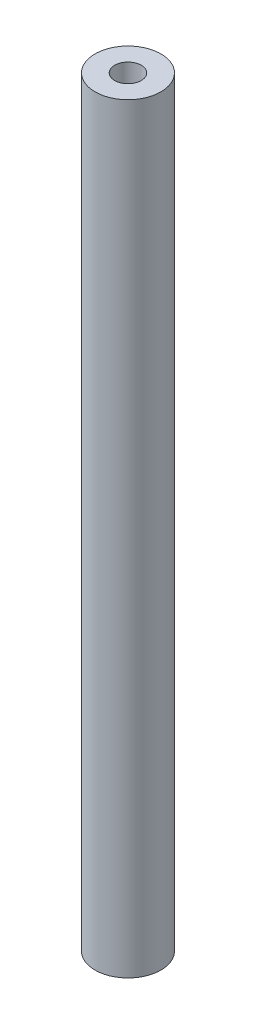
from build123d import *

# Parameters (mm, degrees)
SKETCH1_R                                = 5
BOSS_EXTRUDE2_DEPTH                      = 115.57
CUT_EXTRUDE1_DEPTH                       = 2.54
TAP_DRILL_FOR_10_32_TAP1_D               = 4.0386
TAP_DRILL_FOR_10_32_TAP1_DEPTH           = 11.486682152
TAP_DRILL_FOR_10_32_TAP1_TIP             = 1.213317848
TAP_DRILL_FOR_10_32_TAP1_ON_FACE_2_D     = 4.0386
TAP_DRILL_FOR_10_32_TAP1_ON_FACE_2_DEPTH = 11.486682152
TAP_DRILL_FOR_10_32_TAP1_ON_FACE_2_TIP   = 1.213317848


with BuildPart() as part:
    # Sketch1 → Boss-Extrude2 (new body)
    with BuildSketch(Plane(origin=(0, 0, 0), x_dir=(1, 0, 0), z_dir=(0, 1, 0))):
        Circle(SKETCH1_R)
    extrude(amount=-BOSS_EXTRUDE2_DEPTH)

    # Sketch2 → Cut-Extrude1 (cut)
    with BuildSketch(Plane(origin=(0, 0, -5), x_dir=(-1, 0, 0), z_dir=(0, 0, -1))):
        with BuildLine():
            Line((-2, -109.22), (-2, -114.22))
            ThreePointArc((-2, -114.22), (0, -116.22), (2, -114.22))
            Line((2, -114.22), (2, -109.22))
            ThreePointArc((2, -109.22), (0, -107.22), (-2, -109.22))
        make_face()
        with BuildLine():
            Line((-1.5, -63.5), (-1.5, -68.5))
            ThreePointArc((-1.5, -68.5), (0, -70), (1.5, -68.5))
            Line((1.5, -68.5), (1.5, -63.5))
            ThreePointArc((1.5, -63.5), (0, -62), (-1.5, -63.5))
        make_face()
        with BuildLine():
            Line((-1.5, -10.39), (-1.5, -15.39))
            ThreePointArc((-1.5, -15.39), (0, -16.89), (1.5, -15.39))
            Line((1.5, -15.39), (1.5, -10.39))
            ThreePointArc((1.5, -10.39), (0, -8.89), (-1.5, -10.39))
        make_face()
    extrude(amount=-CUT_EXTRUDE1_DEPTH, mode=Mode.SUBTRACT)

    # Tap Drill for #10-32 Tap1
    with Locations(Plane.ZX):
        with Locations((0, 0)):
            Hole(TAP_DRILL_FOR_10_32_TAP1_D / 2, depth=TAP_DRILL_FOR_10_32_TAP1_DEPTH)
            with Locations((0, 0, -(TAP_DRILL_FOR_10_32_TAP1_DEPTH + TAP_DRILL_FOR_10_32_TAP1_TIP / 2))):  # 118° drill point
                Cone(0, TAP_DRILL_FOR_10_32_TAP1_D / 2, TAP_DRILL_FOR_10_32_TAP1_TIP, mode=Mode.SUBTRACT)

    # Tap Drill for #10-32 Tap1 on face 2
    with Locations(Plane(origin=(0, -115.57, 0), x_dir=(0, 0, -1), z_dir=(0, -1, 0))):
        with Locations((0, 0)):
            Hole(TAP_DRILL_FOR_10_32_TAP1_ON_FACE_2_D / 2, depth=TAP_DRILL_FOR_10_32_TAP1_ON_FACE_2_DEPTH)
            with Locations((0, 0, -(TAP_DRILL_FOR_10_32_TAP1_ON_FACE_2_DEPTH + TAP_DRILL_FOR_10_32_TAP1_ON_FACE_2_TIP / 2))):  # 118° drill point
                Cone(0, TAP_DRILL_FOR_10_32_TAP1_ON_FACE_2_D / 2, TAP_DRILL_FOR_10_32_TAP1_ON_FACE_2_TIP, mode=Mode.SUBTRACT)


solid = part.part
